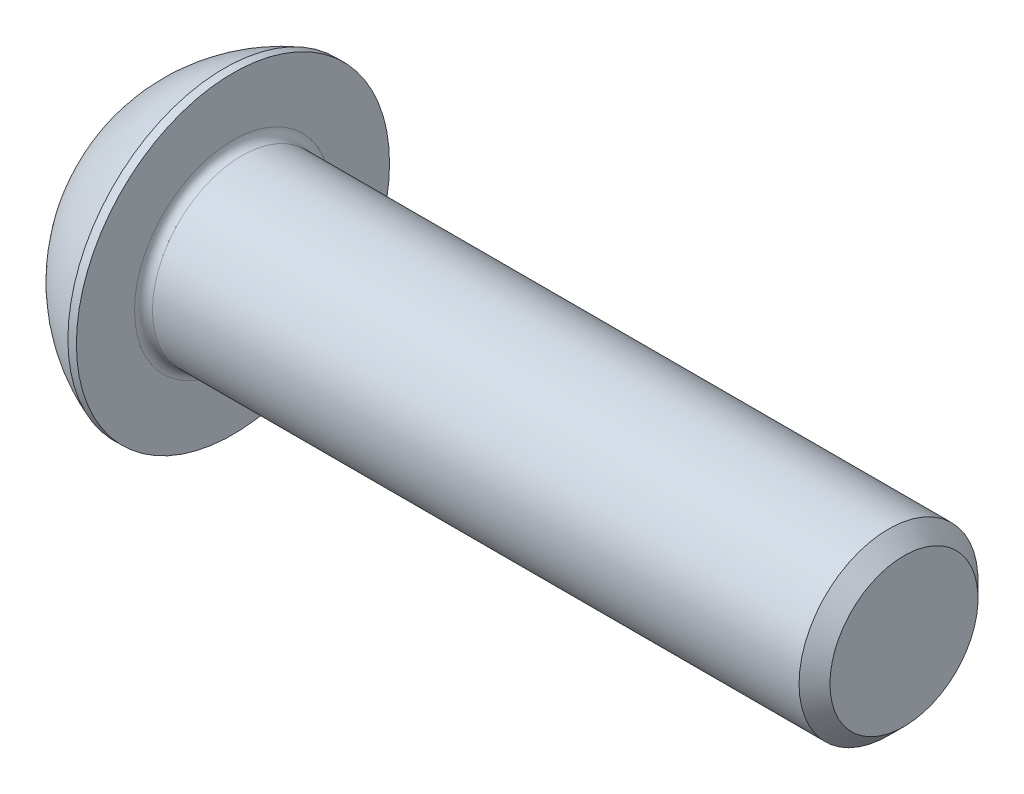
from build123d import *

# Parameters (mm, degrees)
FILLET1_R   = 0.4
HEX_2_DEPTH = 2.6


with BuildPart() as part:
    # BodySke → BaseBody (revolve)
    with BuildSketch(Plane.XY, mode=Mode.PRIVATE) as basebody_sk:
        with BuildLine():
            Line((34.4, 0), (34.4, 3.3095))
            Line((34.4, 3.3095), (33.7095, 4))
            Line((33.7095, 4), (4.4, 4))
            Line((4.4, 4), (4.4, 7))
            Line((4.4, 7), (4.02, 7))
            ThreePointArc((4.02, 7), (1.686451133, 5.621618984), (0, 3.5))
            Line((0, 3.5), (0, 0))
            Line((0, 0), (34.4, 0))
        make_face()
    revolve(basebody_sk.sketch.rotate(Axis((0, 0, 0), (1, 0, 0)), 90), axis=Axis((0, 0, 0), (1, 0, 0)))  # turned: the seam where the file's is

    # Fillet1
    fillet1_edges = [part.edges().sort_by_distance(p)[0] for p in [
        (4.4, 0, -4),
    ]]
    fillet(fillet1_edges, radius=FILLET1_R)

    # Sketch2 → PreBroach (revolve, cut)
    with BuildSketch(Plane.XY, mode=Mode.PRIVATE) as prebroach_sk:
        Polygon((0, 2.5), (2.6, 2.5), (4.043375673, 0), (0, 0), align=None)
    revolve(prebroach_sk.sketch.rotate(Axis((0, 0, 0), (1, 0, 0)), 90), axis=Axis((0, 0, 0), (1, 0, 0)), mode=Mode.SUBTRACT)  # turned: the seam where the file's is

    # Sketch3 → Hex 2 (cut)
    with BuildSketch(Plane(origin=(0, 0, 0), x_dir=(0, 0, -1), z_dir=(1, 0, 0))):
        Polygon((-2.5, -1.443375673), (-2.5, 1.443375673), (0, 2.886751346), (2.5, 1.443375673), (2.5, -1.443375673), (0, -2.886751346), align=None)
    extrude(amount=HEX_2_DEPTH, mode=Mode.SUBTRACT)


solid = part.part
